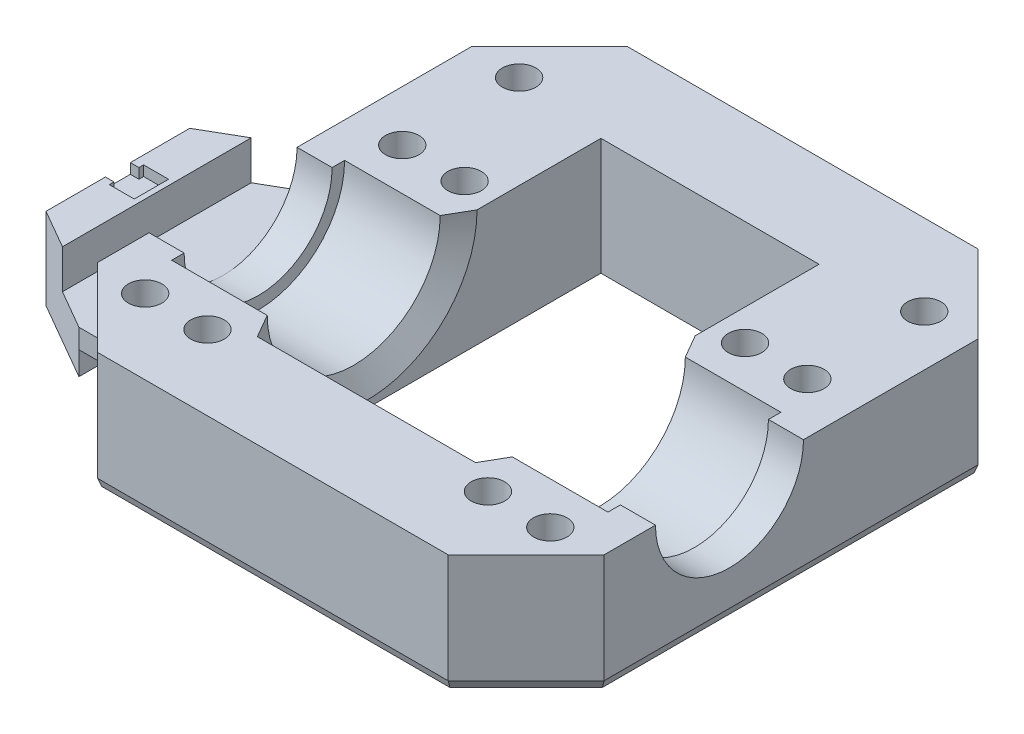
from build123d import *

# Parameters (mm, degrees)
SKETCH1_W              = 65
SKETCH1_H              = 100
SKETCH1_W_2            = 28
SKETCH1_H_2            = 80
BOSS_EXTRUDE1_DEPTH    = 15
SKETCH3_W              = 14
SKETCH3_H              = 11.1
SKETCH4_R              = 9.5
CUT_EXTRUDE2_DEPTH     = 66
SKETCH8_R              = 2.15
CUT_EXTRUDE6_DEPTH     = 16
FILLET1_R              = 20
CHAMFER1_SIZE          = 3
CHAMFER1_SIZE2         = 1.732050808
CHAMFER1_PART_2_SIZE   = 3
CHAMFER1_PART_2_SIZE2  = 1.732050808
SKETCH10_W             = 30
SKETCH10_H             = 5.5
BOSS_EXTRUDE2_DEPTH    = 13.5
BOSS_EXTRUDE3_START    = 7
SKETCH12_W             = 30
SKETCH12_H             = 3.7
BOSS_EXTRUDE3_DEPTH    = 6.5
BOSS_EXTRUDE4_DEPTH    = 1.3
CHAMFER3_SIZE          = 10
CHAMFER3_SIZE2         = 5.773502692
CHAMFER3_PART_2_SIZE   = 10
CHAMFER3_PART_2_SIZE2  = 5.773502692
BOSS_EXTRUDE6_DEPTH    = 28
SKETCH16_W             = 65
SKETCH16_H             = 26.184127578
CUT_EXTRUDE7_DEPTH     = 16
SKETCH17_W             = 28
SKETCH17_H             = 10
BOSS_EXTRUDE7_DEPTH    = 15
SKETCH18_W             = 65
SKETCH18_H             = 20
BOSS_EXTRUDE8_DEPTH    = 15
SKETCH19_W             = 65
SKETCH19_H             = 8.1
CUT_EXTRUDE8_DEPTH     = 16
CUT_EXTRUDE10_DEPTH    = 3
CHAMFER5_SIZE          = 10
CHAMFER6_SIZE          = 1
CHAMFER6_SIZE2         = 0.363970234
CHAMFER6_PART_2_SIZE   = 1
CHAMFER6_PART_2_SIZE2  = 0.363970234
CHAMFER6_PART_3_SIZE   = 1
CHAMFER6_PART_3_SIZE2  = 0.363970234
CHAMFER6_PART_4_SIZE   = 1
CHAMFER6_PART_4_SIZE2  = 0.363970234
CHAMFER6_PART_5_SIZE   = 1
CHAMFER6_PART_5_SIZE2  = 0.363970234
CHAMFER6_PART_6_SIZE   = 1
CHAMFER6_PART_6_SIZE2  = 0.363970234
CHAMFER6_PART_7_SIZE   = 1
CHAMFER6_PART_7_SIZE2  = 0.363970234
CHAMFER6_PART_8_SIZE   = 1
CHAMFER6_PART_8_SIZE2  = 0.363970234
SKETCH26_R             = 2.15
CUT_EXTRUDE11_DEPTH    = 16
CHAMFER7_SIZE          = 0.6
CHAMFER7_SIZE2         = 0.218382141
CHAMFER7_PART_2_SIZE   = 0.6
CHAMFER7_PART_2_SIZE2  = 0.218382141
CHAMFER7_PART_3_SIZE   = 0.6
CHAMFER7_PART_3_SIZE2  = 0.218382141
CHAMFER7_PART_4_SIZE   = 0.6
CHAMFER7_PART_4_SIZE2  = 0.218382141
CHAMFER7_PART_5_SIZE   = 0.6
CHAMFER7_PART_5_SIZE2  = 0.218382141
CHAMFER7_PART_6_SIZE   = 0.6
CHAMFER7_PART_6_SIZE2  = 0.218382141
CHAMFER7_PART_7_SIZE   = 0.6
CHAMFER7_PART_7_SIZE2  = 0.218382141
CHAMFER7_PART_8_SIZE   = 0.6
CHAMFER7_PART_8_SIZE2  = 0.218382141
CHAMFER7_PART_9_SIZE   = 0.6
CHAMFER7_PART_9_SIZE2  = 0.218382141
CHAMFER7_PART_10_SIZE  = 0.6
CHAMFER7_PART_10_SIZE2 = 0.218382141
CUT_EXTRUDE12_DEPTH    = 5


with BuildPart() as part:
    # Sketch1 → Boss-Extrude1 (new body)
    with BuildSketch(Plane(origin=(0, 0, 0), x_dir=(1, 0, 0), z_dir=(0, 1, 0))):
        Rectangle(SKETCH1_W, SKETCH1_H)
        Rectangle(SKETCH1_W_2, SKETCH1_H_2, mode=Mode.SUBTRACT)
    extrude(amount=BOSS_EXTRUDE1_DEPTH)

    # Sketch3 → Cut-Revolve1 (revolve, cut)
    with BuildSketch(Plane(origin=(0, 15, 0), x_dir=(1, 0, 0), z_dir=(0, 1, 0))):
        with Locations((21, -5.55)):
            Rectangle(SKETCH3_W, SKETCH3_H)
        with Locations((-21, -5.55)):
            Rectangle(SKETCH3_W, SKETCH3_H)
    revolve(axis=Axis((14, 15, 0), (1, 0, 0)), mode=Mode.SUBTRACT)

    # Sketch4 → Cut-Extrude2 (cut, through all)
    with BuildSketch(Plane(origin=(32.5, 0, 0), x_dir=(0, 0, -1), z_dir=(1, 0, 0))):
        with Locations((0, 15)):
            Circle(SKETCH4_R)
    extrude(amount=-CUT_EXTRUDE2_DEPTH, mode=Mode.SUBTRACT)

    # Sketch8 → Cut-Extrude6 (cut, through all)
    with BuildSketch(Plane(origin=(0, 15, 0), x_dir=(1, 0, 0), z_dir=(0, 1, 0))):
        with Locations((18, 16.5)):
            Circle(SKETCH8_R)
        with Locations((18, -16.5)):
            Circle(SKETCH8_R)
        with Locations((-18, -16.5)):
            Circle(SKETCH8_R)
        with Locations((-18, 16.5)):
            Circle(SKETCH8_R)
        with Locations((9, -27)):
            Circle(SKETCH8_R)
        with Locations((-9, -27)):
            Circle(SKETCH8_R)
        with Locations((-9, 27)):
            Circle(SKETCH8_R)
        with Locations((9, 27)):
            Circle(SKETCH8_R)
        with Locations((-26, 16.5)):
            Circle(SKETCH8_R)
        with Locations((26, 16.5)):
            Circle(SKETCH8_R)
        with Locations((26, -16.5)):
            Circle(SKETCH8_R)
        with Locations((-26, -16.5)):
            Circle(SKETCH8_R)
    extrude(amount=-CUT_EXTRUDE6_DEPTH, mode=Mode.SUBTRACT)

    # Fillet1
    fillet1_edges = [part.edges().sort_by_distance(p)[0] for p in [
        (-32.5, 7.5, -50),
        (32.5, 7.5, -50),
        (32.5, 7.5, 50),
        (-32.5, 7.5, 50),
    ]]
    fillet(fillet1_edges, radius=FILLET1_R)

    # Chamfer1
    chamfer1_edges = [part.edges().sort_by_distance(p)[0] for p in [
        (14, 3.9, 0),
    ]]
    chamfer1_side = [part.faces().sort_by_distance(p)[0] for p in [
        (14, 0.81394103, 0),
    ]]
    chamfer(chamfer1_edges, length=CHAMFER1_SIZE, length2=CHAMFER1_SIZE2, reference=chamfer1_side[0])

    # Chamfer1 part 2
    chamfer1_part_2_edges = [part.edges().sort_by_distance(p)[0] for p in [
        (-14, 3.9, 0),
    ]]
    chamfer1_part_2_side = [part.faces().sort_by_distance(p)[0] for p in [
        (-14, 0.81394103, 0),
    ]]
    chamfer(chamfer1_part_2_edges, length=CHAMFER1_PART_2_SIZE, length2=CHAMFER1_PART_2_SIZE2, reference=chamfer1_part_2_side[0])

    # Sketch10 → Boss-Extrude2 (add)
    with BuildSketch(Plane.ZY.offset(32.5)):
        with Locations((0, 2.75)):
            Rectangle(SKETCH10_W, SKETCH10_H)
    extrude(amount=BOSS_EXTRUDE2_DEPTH)

    # Sketch12 → Boss-Extrude3 (add)
    with BuildSketch(Plane.ZY.offset(32.5).offset(BOSS_EXTRUDE3_START)):
        with Locations((0, 7.35)):
            Rectangle(SKETCH12_W, SKETCH12_H)
    extrude(amount=BOSS_EXTRUDE3_DEPTH)

    # Sketch13 → Boss-Extrude4 (add)
    with BuildSketch(Plane(origin=(0, 9.2, 0), x_dir=(1, 0, 0), z_dir=(0, 1, 0))):
        Polygon((-44.9, 2.2), (-44.9, 1.6), (-46, 1.6), (-46, 15), (-39, 15), (-39, -15), (-46, -15), (-46, -1.6), (-44.9, -1.6), (-44.9, -2.2), (-41.7, -2.2), (-41.7, 2.2), align=None)
    extrude(amount=BOSS_EXTRUDE4_DEPTH)

    # Chamfer3
    chamfer3_edges = [part.edges().sort_by_distance(p)[0] for p in [
        (-46, 5.25, -15),
    ]]
    chamfer3_side = [part.faces().sort_by_distance(p)[0] for p in [
        (-40.309124767, 4.381657356, -15),
    ]]
    chamfer(chamfer3_edges, length=CHAMFER3_SIZE, length2=CHAMFER3_SIZE2, reference=chamfer3_side[0])

    # Chamfer3 part 2
    chamfer3_part_2_edges = [part.edges().sort_by_distance(p)[0] for p in [
        (-46, 5.25, 15),
    ]]
    chamfer3_part_2_side = [part.faces().sort_by_distance(p)[0] for p in [
        (-40.309124767, 4.381657356, 15),
    ]]
    chamfer(chamfer3_part_2_edges, length=CHAMFER3_PART_2_SIZE, length2=CHAMFER3_PART_2_SIZE2, reference=chamfer3_part_2_side[0])

    # Sketch15 → Boss-Extrude6 (add)
    with BuildSketch(Plane(origin=(-14, 0, 0), x_dir=(0, 0, -1), z_dir=(1, 0, 0))):
        with BuildLine():
            Line((-12.8, 9.086456223), (-12.8, 0))
            Line((-12.8, 0), (-40, 0))
            Line((-40, 0), (-40, 15))
            Line((-40, 15), (-14.1, 15))
            ThreePointArc((-14.1, 15), (-13.771165528, 11.972624899), (-12.8, 9.086456223))
        make_face()
    extrude(amount=BOSS_EXTRUDE6_DEPTH)

    # Sketch16 → Cut-Extrude7 (cut, through all)
    with BuildSketch(Plane(origin=(0, 15, 0), x_dir=(1, 0, 0), z_dir=(0, 1, 0))):
        with Locations((0, -39.192063789)):
            Rectangle(SKETCH16_W, SKETCH16_H)
    extrude(amount=-CUT_EXTRUDE7_DEPTH, mode=Mode.SUBTRACT)

    # Sketch17 → Boss-Extrude7 (add)
    with BuildSketch(Plane(origin=(0, 15, 0), x_dir=(1, 0, 0), z_dir=(0, 1, 0))):
        with Locations((0, 35)):
            Rectangle(SKETCH17_W, SKETCH17_H)
    extrude(amount=-BOSS_EXTRUDE7_DEPTH)

    # Sketch18 → Boss-Extrude8 (add)
    with BuildSketch(Plane(origin=(0, 15, 0), x_dir=(1, 0, 0), z_dir=(0, 1, 0))):
        with Locations((0, 40)):
            Rectangle(SKETCH18_W, SKETCH18_H)
    extrude(amount=-BOSS_EXTRUDE8_DEPTH)

    # Sketch19 → Cut-Extrude8 (cut, through all)
    with BuildSketch(Plane(origin=(0, 15, 0), x_dir=(1, 0, 0), z_dir=(0, 1, 0))):
        with Locations((0, 45.95)):
            Rectangle(SKETCH19_W, SKETCH19_H)
    extrude(amount=-CUT_EXTRUDE8_DEPTH, mode=Mode.SUBTRACT)

    # Sketch21 → Cut-Extrude10 (cut)
    with BuildSketch(Plane.XZ):
        Polygon((-32.5, -8.25), (-32.5, 15), (-36, 15), (-36, 1.75), (-46, 1.75), (-46, -1.75), (-46, -8.25), align=None)
    extrude(amount=-CUT_EXTRUDE10_DEPTH, mode=Mode.SUBTRACT)

    # Chamfer5
    chamfer5_edges = [part.edges().sort_by_distance(p)[0] for p in [
        (-32.5, 7.5, 26.1),
        (32.5, 7.5, 26.1),
        (32.5, 7.5, -41.9),
        (-32.5, 7.5, -41.9),
    ]]
    chamfer(chamfer5_edges, length=CHAMFER5_SIZE)

    # Chamfer6
    chamfer6_edges = [part.edges().sort_by_distance(p)[0] for p in [
        (-27.5, 0, 21.1),
    ]]
    chamfer6_side = [part.faces().sort_by_distance(p)[0] for p in [
        (-27.5, 7.5, 21.1),
    ]]
    chamfer(chamfer6_edges, length=CHAMFER6_SIZE, length2=CHAMFER6_SIZE2, reference=chamfer6_side[0])

    # Chamfer6 part 2
    chamfer6_part_2_edges = [part.edges().sort_by_distance(p)[0] for p in [
        (0, 0, 26.1),
    ]]
    chamfer6_part_2_side = [part.faces().sort_by_distance(p)[0] for p in [
        (0, 7.5, 26.1),
    ]]
    chamfer(chamfer6_part_2_edges, length=CHAMFER6_PART_2_SIZE, length2=CHAMFER6_PART_2_SIZE2, reference=chamfer6_part_2_side[0])

    # Chamfer6 part 3
    chamfer6_part_3_edges = [part.edges().sort_by_distance(p)[0] for p in [
        (27.5, 0, 21.1),
    ]]
    chamfer6_part_3_side = [part.faces().sort_by_distance(p)[0] for p in [
        (27.5, 7.5, 21.1),
    ]]
    chamfer(chamfer6_part_3_edges, length=CHAMFER6_PART_3_SIZE, length2=CHAMFER6_PART_3_SIZE2, reference=chamfer6_part_3_side[0])

    # Chamfer6 part 4
    chamfer6_part_4_edges = [part.edges().sort_by_distance(p)[0] for p in [
        (-32.5, 0, -23.45),
    ]]
    chamfer6_part_4_side = [part.faces().sort_by_distance(p)[0] for p in [
        (-32.5, 7.949222644, -20.692601289),
    ]]
    chamfer(chamfer6_part_4_edges, length=CHAMFER6_PART_4_SIZE, length2=CHAMFER6_PART_4_SIZE2, reference=chamfer6_part_4_side[0])

    # Chamfer6 part 5
    chamfer6_part_5_edges = [part.edges().sort_by_distance(p)[0] for p in [
        (-27.5, 0, -36.9),
    ]]
    chamfer6_part_5_side = [part.faces().sort_by_distance(p)[0] for p in [
        (-27.5, 7.5, -36.9),
    ]]
    chamfer(chamfer6_part_5_edges, length=CHAMFER6_PART_5_SIZE, length2=CHAMFER6_PART_5_SIZE2, reference=chamfer6_part_5_side[0])

    # Chamfer6 part 6
    chamfer6_part_6_edges = [part.edges().sort_by_distance(p)[0] for p in [
        (32.5, 0, -7.9),
    ]]
    chamfer6_part_6_side = [part.faces().sort_by_distance(p)[0] for p in [
        (32.5, 6.649742071, -9.836820303),
    ]]
    chamfer(chamfer6_part_6_edges, length=CHAMFER6_PART_6_SIZE, length2=CHAMFER6_PART_6_SIZE2, reference=chamfer6_part_6_side[0])

    # Chamfer6 part 7
    chamfer6_part_7_edges = [part.edges().sort_by_distance(p)[0] for p in [
        (27.5, 0, -36.9),
    ]]
    chamfer6_part_7_side = [part.faces().sort_by_distance(p)[0] for p in [
        (27.5, 7.5, -36.9),
    ]]
    chamfer(chamfer6_part_7_edges, length=CHAMFER6_PART_7_SIZE, length2=CHAMFER6_PART_7_SIZE2, reference=chamfer6_part_7_side[0])

    # Chamfer6 part 8
    chamfer6_part_8_edges = [part.edges().sort_by_distance(p)[0] for p in [
        (0, 0, -41.9),
    ]]
    chamfer6_part_8_side = [part.faces().sort_by_distance(p)[0] for p in [
        (0, 7.5, -41.9),
    ]]
    chamfer(chamfer6_part_8_edges, length=CHAMFER6_PART_8_SIZE, length2=CHAMFER6_PART_8_SIZE2, reference=chamfer6_part_8_side[0])

    # Sketch26 → Cut-Extrude11 (cut, through all)
    with BuildSketch(Plane(origin=(0, 15, 0), x_dir=(1, 0, 0), z_dir=(0, 1, 0))):
        with Locations((-26, 31.5)):
            Circle(SKETCH26_R)
        with Locations((26, 31.5)):
            Circle(SKETCH26_R)
    extrude(amount=-CUT_EXTRUDE11_DEPTH, mode=Mode.SUBTRACT)

    # Chamfer7
    chamfer7_edges = [part.edges().sort_by_distance(p)[0] for p in [
        (-28.15, 0, -31.5),
    ]]
    chamfer7_side = [part.faces().sort_by_distance(p)[0] for p in [
        (-28.15, 7.5, -31.5),
    ]]
    chamfer(chamfer7_edges, length=CHAMFER7_SIZE, length2=CHAMFER7_SIZE2, reference=chamfer7_side[0])

    # Chamfer7 part 2
    chamfer7_part_2_edges = [part.edges().sort_by_distance(p)[0] for p in [
        (23.85, 0, -31.5),
    ]]
    chamfer7_part_2_side = [part.faces().sort_by_distance(p)[0] for p in [
        (23.85, 7.5, -31.5),
    ]]
    chamfer(chamfer7_part_2_edges, length=CHAMFER7_PART_2_SIZE, length2=CHAMFER7_PART_2_SIZE2, reference=chamfer7_part_2_side[0])

    # Chamfer7 part 3
    chamfer7_part_3_edges = [part.edges().sort_by_distance(p)[0] for p in [
        (15.85, 0, -16.5),
    ]]
    chamfer7_part_3_side = [part.faces().sort_by_distance(p)[0] for p in [
        (15.85, 7.5, -16.5),
    ]]
    chamfer(chamfer7_part_3_edges, length=CHAMFER7_PART_3_SIZE, length2=CHAMFER7_PART_3_SIZE2, reference=chamfer7_part_3_side[0])

    # Chamfer7 part 4
    chamfer7_part_4_edges = [part.edges().sort_by_distance(p)[0] for p in [
        (23.85, 0, -16.5),
    ]]
    chamfer7_part_4_side = [part.faces().sort_by_distance(p)[0] for p in [
        (23.85, 7.5, -16.5),
    ]]
    chamfer(chamfer7_part_4_edges, length=CHAMFER7_PART_4_SIZE, length2=CHAMFER7_PART_4_SIZE2, reference=chamfer7_part_4_side[0])

    # Chamfer7 part 5
    chamfer7_part_5_edges = [part.edges().sort_by_distance(p)[0] for p in [
        (23.85, 0, 16.5),
    ]]
    chamfer7_part_5_side = [part.faces().sort_by_distance(p)[0] for p in [
        (23.85, 7.5, 16.5),
    ]]
    chamfer(chamfer7_part_5_edges, length=CHAMFER7_PART_5_SIZE, length2=CHAMFER7_PART_5_SIZE2, reference=chamfer7_part_5_side[0])

    # Chamfer7 part 6
    chamfer7_part_6_edges = [part.edges().sort_by_distance(p)[0] for p in [
        (-28.15, 0, 16.5),
    ]]
    chamfer7_part_6_side = [part.faces().sort_by_distance(p)[0] for p in [
        (-28.15, 7.5, 16.5),
    ]]
    chamfer(chamfer7_part_6_edges, length=CHAMFER7_PART_6_SIZE, length2=CHAMFER7_PART_6_SIZE2, reference=chamfer7_part_6_side[0])

    # Chamfer7 part 7
    chamfer7_part_7_edges = [part.edges().sort_by_distance(p)[0] for p in [
        (15.85, 0, 16.5),
    ]]
    chamfer7_part_7_side = [part.faces().sort_by_distance(p)[0] for p in [
        (15.85, 7.5, 16.5),
    ]]
    chamfer(chamfer7_part_7_edges, length=CHAMFER7_PART_7_SIZE, length2=CHAMFER7_PART_7_SIZE2, reference=chamfer7_part_7_side[0])

    # Chamfer7 part 8
    chamfer7_part_8_edges = [part.edges().sort_by_distance(p)[0] for p in [
        (-20.15, 0, 16.5),
    ]]
    chamfer7_part_8_side = [part.faces().sort_by_distance(p)[0] for p in [
        (-20.15, 7.5, 16.5),
    ]]
    chamfer(chamfer7_part_8_edges, length=CHAMFER7_PART_8_SIZE, length2=CHAMFER7_PART_8_SIZE2, reference=chamfer7_part_8_side[0])

    # Chamfer7 part 9
    chamfer7_part_9_edges = [part.edges().sort_by_distance(p)[0] for p in [
        (-28.15, 0, -16.5),
    ]]
    chamfer7_part_9_side = [part.faces().sort_by_distance(p)[0] for p in [
        (-28.15, 7.5, -16.5),
    ]]
    chamfer(chamfer7_part_9_edges, length=CHAMFER7_PART_9_SIZE, length2=CHAMFER7_PART_9_SIZE2, reference=chamfer7_part_9_side[0])

    # Chamfer7 part 10
    chamfer7_part_10_edges = [part.edges().sort_by_distance(p)[0] for p in [
        (-20.15, 0, -16.5),
    ]]
    chamfer7_part_10_side = [part.faces().sort_by_distance(p)[0] for p in [
        (-20.15, 7.5, -16.5),
    ]]
    chamfer(chamfer7_part_10_edges, length=CHAMFER7_PART_10_SIZE, length2=CHAMFER7_PART_10_SIZE2, reference=chamfer7_part_10_side[0])

    # Sketch27 → Cut-Extrude12 (cut)
    with BuildSketch(Plane(origin=(0, 10.5, 0), x_dir=(1, 0, 0), z_dir=(0, 1, 0))):
        Polygon((-39, 13.267949192), (-39, -13.267949192), (-41, -12.113248654), (-41, 12.113248654), align=None)
    extrude(amount=-CUT_EXTRUDE12_DEPTH, mode=Mode.SUBTRACT)


solid = part.part
